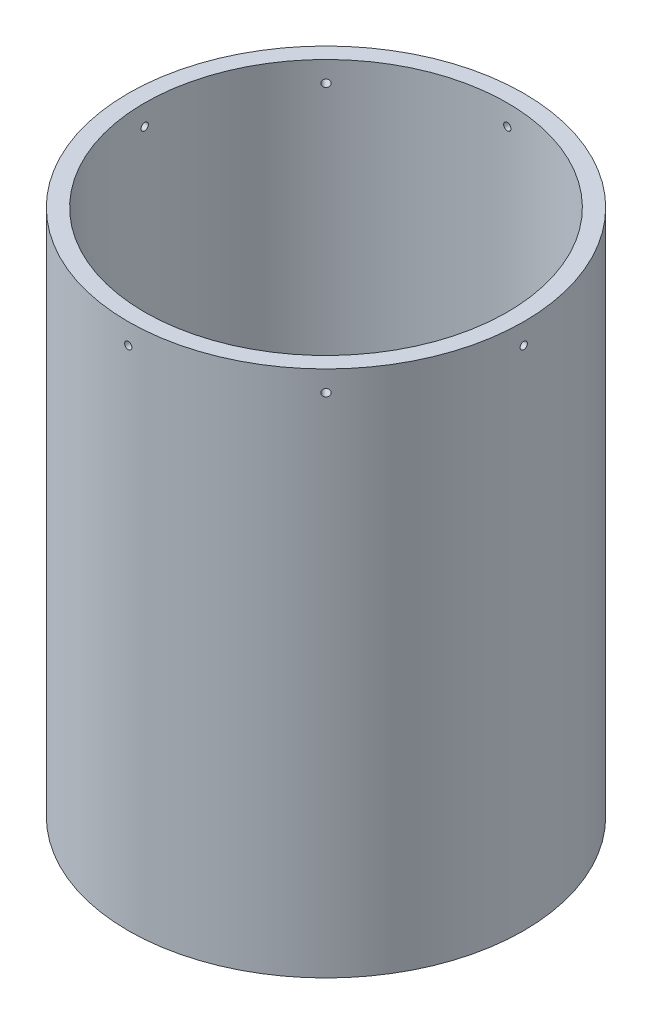
from build123d import *

# Parameters (mm, degrees)
SKETCH1_R                   = 152.4
SKETCH1_R_2                 = 139.7
BOSS_EXTRUDE1_DEPTH         = 406.4
F_10_CLEARANCE_HOLE1_REACH  = 532.368
F_10_CLEARANCE_HOLE1_BORE_R = 2.8067
CIRPATTERN1_COUNT           = 8
F_8_32_TAPPED_HOLE1_REACH   = 550.207
F_8_32_TAPPED_HOLE1_BORE_R  = 1.7272


with BuildPart() as part:
    # Sketch1 → Boss-Extrude1 (new body)
    with BuildSketch(Plane(origin=(0, 0, 0), x_dir=(1, 0, 0), z_dir=(0, 1, 0))):
        with Locations(Location((0, 0, 0), (0, 0, 270))):
            Circle(SKETCH1_R)
        with Locations(Location((0, 0, 0), (0, 0, 270))):
            Circle(SKETCH1_R_2, mode=Mode.SUBTRACT)
    extrude(amount=BOSS_EXTRUDE1_DEPTH)

    # #10 Clearance Hole1 bore → #10 Clearance Hole1 (cut, up to next)
    with BuildSketch(Plane(origin=(152.4, 0, 0), x_dir=(0, 0, -1), z_dir=(1, 0, 0)), mode=Mode.PRIVATE) as f_10_clearance_hole1_sk1:
        with Locations((0, 390.525)):
            Circle(F_10_CLEARANCE_HOLE1_BORE_R)
    f_10_clearance_hole1_tool1 = extrude(f_10_clearance_hole1_sk1.sketch, amount=-F_10_CLEARANCE_HOLE1_REACH, mode=Mode.PRIVATE) & part.part
    f_10_clearance_hole1 = f_10_clearance_hole1_tool1.solids().sort_by_distance((152.4, 390.525, 0))[0]
    add(f_10_clearance_hole1, mode=Mode.SUBTRACT)

    # CirPattern1: #10 Clearance Hole1 ×8 about axis
    cirpattern1_axis = Axis((0, 406.4, 0), (0, 1, 0))
    for i in range(1, CIRPATTERN1_COUNT):
        add(f_10_clearance_hole1.rotate(cirpattern1_axis, i * 360 / CIRPATTERN1_COUNT), mode=Mode.SUBTRACT)

    # #8-32 Tapped Hole1 bore → #8-32 Tapped Hole1 (cut, up to next)
    with BuildSketch(Plane(origin=(-107.763073453, 0, -107.763073453), x_dir=(0, -1, 0), z_dir=(-0.7071067811865464, 0, -0.7071067811865488)), mode=Mode.PRIVATE) as f_8_32_tapped_hole1_sk1:
        with Locations((-127, -8.5725)):
            Circle(F_8_32_TAPPED_HOLE1_BORE_R)
    f_8_32_tapped_hole1_tool1 = extrude(f_8_32_tapped_hole1_sk1.sketch, amount=-F_8_32_TAPPED_HOLE1_REACH, mode=Mode.PRIVATE) & part.part
    # #8-32 Tapped Hole1 bore → #8-32 Tapped Hole1 (cut, up to next)
    with BuildSketch(Plane(origin=(-107.763073453, 0, -107.763073453), x_dir=(0, -1, 0), z_dir=(-0.7071067811865464, 0, -0.7071067811865488)), mode=Mode.PRIVATE) as f_8_32_tapped_hole1_sk2:
        with Locations((-127, 8.5725)):
            Circle(F_8_32_TAPPED_HOLE1_BORE_R)
    f_8_32_tapped_hole1_tool2 = extrude(f_8_32_tapped_hole1_sk2.sketch, amount=-F_8_32_TAPPED_HOLE1_REACH, mode=Mode.PRIVATE) & part.part
    add(f_8_32_tapped_hole1_tool1.solids().sort_by_distance((-101.701401, 127, -113.824746))[0], mode=Mode.SUBTRACT)
    add(f_8_32_tapped_hole1_tool2.solids().sort_by_distance((-113.824746, 127, -101.701401))[0], mode=Mode.SUBTRACT)


solid = part.part
